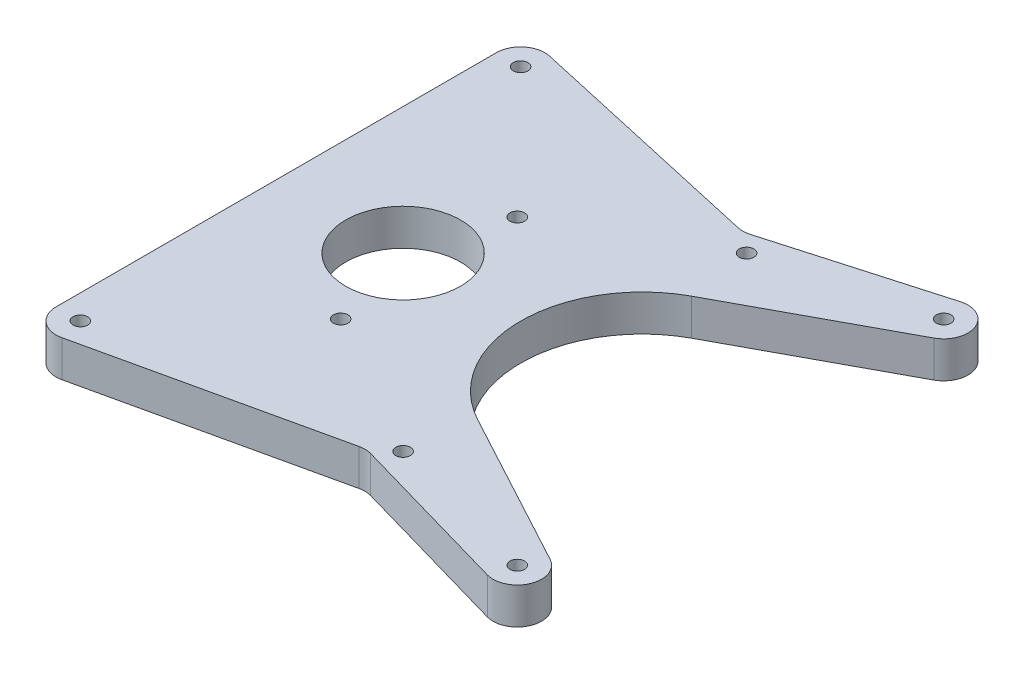
from build123d import *

# Parameters (mm, degrees)
SKETCH2_R           = 1.905
SKETCH2_R_2         = 15.012499947
BOSS_EXTRUDE1_DEPTH = 4.7625


with BuildPart() as part:
    # Sketch2 → Boss-Extrude1 (new, symmetric)
    with BuildSketch(Plane(origin=(0, 0, 0), x_dir=(1, 0, 0), z_dir=(0, 1, 0))):
        with BuildLine():
            Line((47.431459746, 27.946405755), (88.599086108, 50.143751648))
            ThreePointArc((88.599086108, 50.143751648), (91.466763895, 58.127150721), (83.838709673, 61.83808395))
            Line((83.838709673, 61.83808395), (41.161290327, 49.627981648))
            ThreePointArc((41.161290327, 49.627981648), (39.600064271, 49.38574116), (38.027358671, 49.536420772))
            Line((38.027358671, 49.536420772), (-25.448996349, 63.747156504))
            ThreePointArc((-25.448996349, 63.747156504), (-30.805729247, 62.50693539), (-33.186259621, 57.550544477))
            Line((-33.186259621, 57.550544477), (-33.186259621, -57.550544477))
            ThreePointArc((-33.186259621, -57.550544477), (-30.805729247, -62.50693539), (-25.448996349, -63.747156504))
            Line((-25.448996349, -63.747156504), (38.027358671, -49.536420772))
            ThreePointArc((38.027358671, -49.536420772), (39.600064271, -49.38574116), (41.161290327, -49.627981648))
            Line((41.161290327, -49.627981648), (83.838709673, -61.83808395))
            ThreePointArc((83.838709673, -61.83808395), (91.466763895, -58.127150721), (88.599086108, -50.143751648))
            Line((88.599086108, -50.143751648), (47.431459746, -27.946405755))
            ThreePointArc((47.431459746, -27.946405755), (30.75, 0), (47.431459746, 27.946405755))
        make_face()
        with Locations((44.901280605, -44.901280605)):
            Circle(SKETCH2_R, mode=Mode.SUBTRACT)
        with Locations((6.766967201, 23.085378057)):
            Circle(SKETCH2_R, mode=Mode.SUBTRACT)
        with Locations((6.766967201, -23.085378057)):
            Circle(SKETCH2_R, mode=Mode.SUBTRACT)
        with Locations((44.901280605, 44.901280605)):
            Circle(SKETCH2_R, mode=Mode.SUBTRACT)
        with Locations((85.585378057, 55.733032799)):
            Circle(SKETCH2_R, mode=Mode.SUBTRACT)
        with Locations((85.585378057, -55.733032799)):
            Circle(SKETCH2_R, mode=Mode.SUBTRACT)
        with Locations((-26.836259621, -57.550544477)):
            Circle(SKETCH2_R, mode=Mode.SUBTRACT)
        with Locations((-26.836259621, 57.550544477)):
            Circle(SKETCH2_R, mode=Mode.SUBTRACT)
        Circle(SKETCH2_R_2, mode=Mode.SUBTRACT)
    extrude(amount=BOSS_EXTRUDE1_DEPTH, both=True)


solid = part.part
